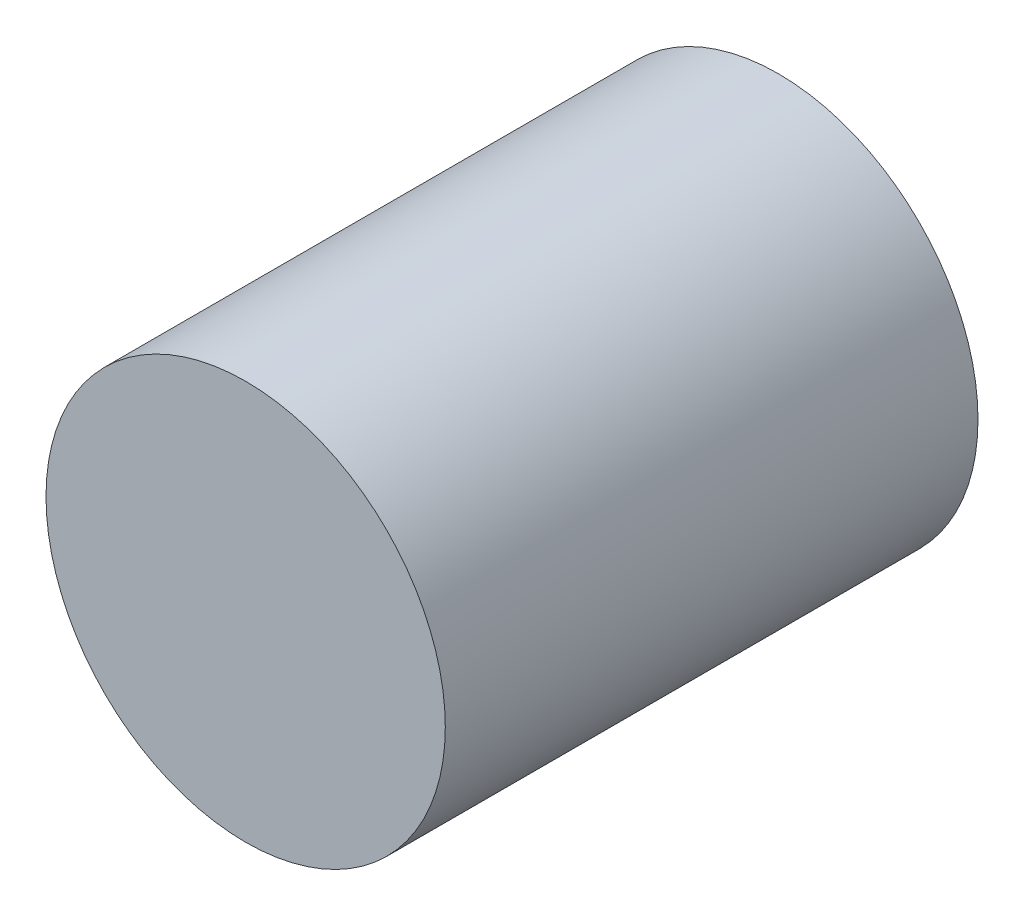
from build123d import *

# Parameters (mm, degrees)
SKETCH1_R           = 4.76
BOSS_EXTRUDE1_DEPTH = 12.7


with BuildPart() as part:
    # Sketch1 → Boss-Extrude1 (new body)
    with BuildSketch(Plane.XY):
        Circle(SKETCH1_R)
    extrude(amount=BOSS_EXTRUDE1_DEPTH)


solid = part.part
